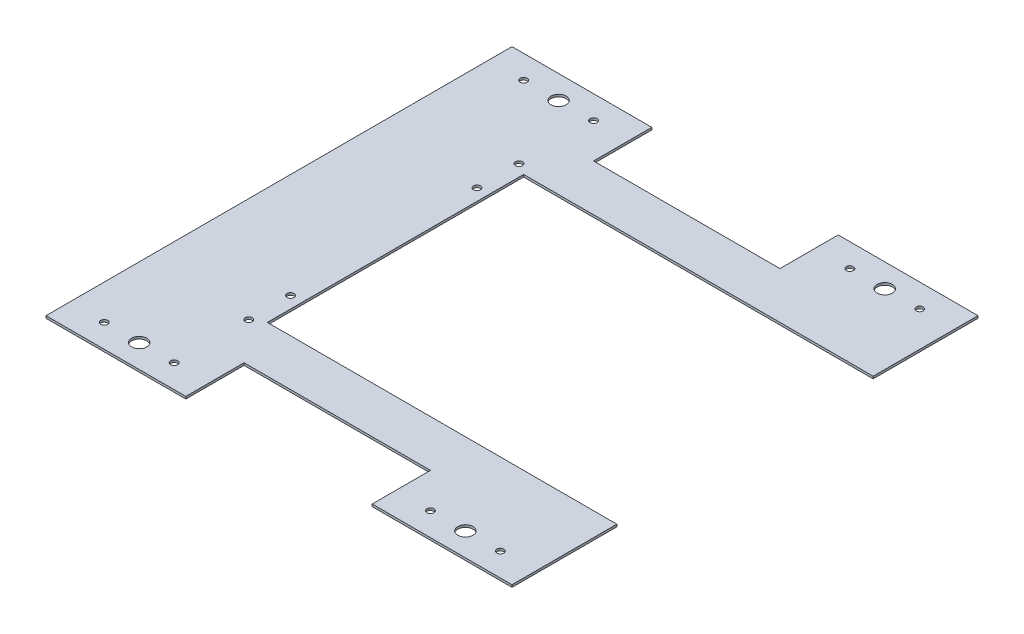
from build123d import *

# Parameters (mm, degrees)
ESQUISSE1_R        = 1.5
ESQUISSE1_R_2      = 3.25
BOSS_EXTRU_1_DEPTH = 1


with BuildPart() as part:
    # Esquisse1 → Boss.-Extru.1 (new body)
    with BuildSketch(Plane(origin=(0, 0, 0), x_dir=(1, 0, 0), z_dir=(0, 1, 0))):
        Polygon((-40, 100), (-40, 75), (40, 75), (40, 100), (100, 100), (100, 55), (-50, 55), (-50, -55), (100, -55), (100, -100), (40, -100), (40, -75), (-40, -75), (-40, -100), (-100, -100), (-100, 100), align=None)
        with Locations((-85, 90)):
            Circle(ESQUISSE1_R, mode=Mode.SUBTRACT)
        with Locations((-55, 90)):
            Circle(ESQUISSE1_R, mode=Mode.SUBTRACT)
        with Locations((-55, -90)):
            Circle(ESQUISSE1_R, mode=Mode.SUBTRACT)
        with Locations((-85, -90)):
            Circle(ESQUISSE1_R, mode=Mode.SUBTRACT)
        with Locations((55, -90)):
            Circle(ESQUISSE1_R, mode=Mode.SUBTRACT)
        with Locations((85, -90)):
            Circle(ESQUISSE1_R, mode=Mode.SUBTRACT)
        with Locations((-55, -58)):
            Circle(ESQUISSE1_R, mode=Mode.SUBTRACT)
        with Locations((-55, -40)):
            Circle(ESQUISSE1_R, mode=Mode.SUBTRACT)
        with Locations((-55, 40)):
            Circle(ESQUISSE1_R, mode=Mode.SUBTRACT)
        with Locations((-55, 58)):
            Circle(ESQUISSE1_R, mode=Mode.SUBTRACT)
        with Locations((-70, -90)):
            Circle(ESQUISSE1_R_2, mode=Mode.SUBTRACT)
        with Locations((70, -90)):
            Circle(ESQUISSE1_R_2, mode=Mode.SUBTRACT)
        with Locations((70, 90)):
            Circle(ESQUISSE1_R_2, mode=Mode.SUBTRACT)
        with Locations((-70, 90)):
            Circle(ESQUISSE1_R_2, mode=Mode.SUBTRACT)
        with Locations((55, 90)):
            Circle(ESQUISSE1_R, mode=Mode.SUBTRACT)
        with Locations((85, 90)):
            Circle(ESQUISSE1_R, mode=Mode.SUBTRACT)
    extrude(amount=BOSS_EXTRU_1_DEPTH)


solid = part.part
